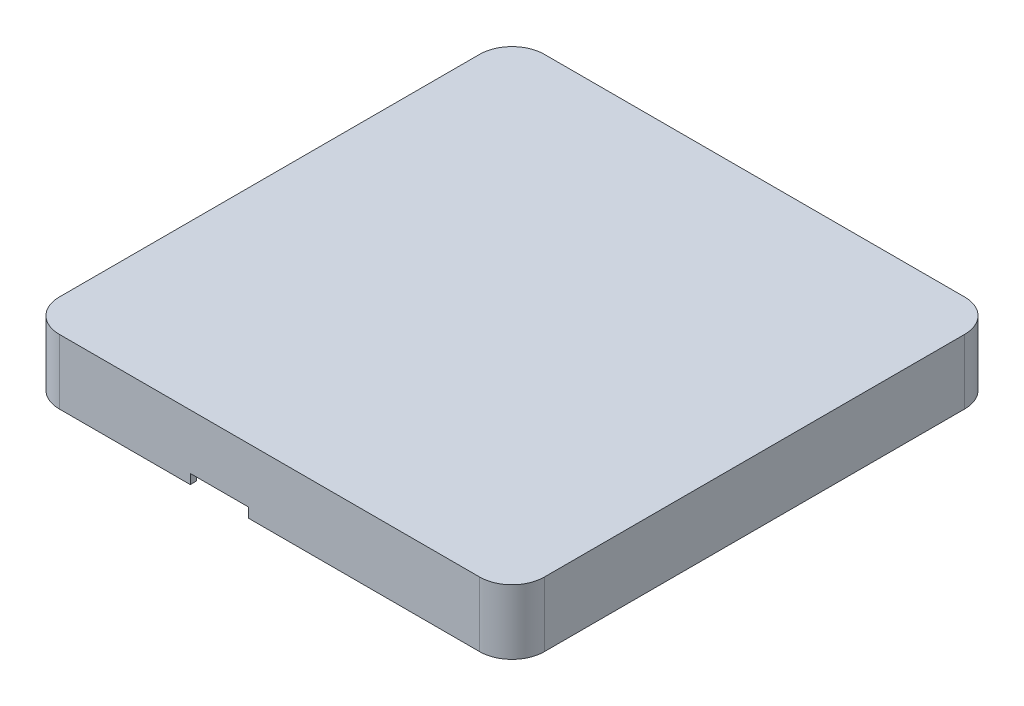
from build123d import *

# Parameters (mm, degrees)
SZKIC1_W                    = 75
SZKIC1_H                    = 75
DODANIE_WYCI_GNI_CIE1_DEPTH = 10
ZAOKR_GLENIE1_R             = 5
WYTNIJ_WYCI_GNI_CIE1_DEPTH  = 8
WYTNIJ_WYCI_GNI_CIE2_DEPTH  = 4
SZKIC7_R                    = 1.9
SZKIC7_R_2                  = 0.9
SZKIC7_R_3                  = 1.900523095
SZKIC7_R_4                  = 0.900523095
DODANIE_WYCI_GNI_CIE2_DEPTH = 8.7
SZKIC9_R                    = 0.900523095
SZKIC9_R_2                  = 0.9
DODANIE_WYCI_GNI_CIE3_DEPTH = 1
SZKIC10_R                   = 1.7
DODANIE_WYCI_GNI_CIE4_DEPTH = 1
SZKIC11_R                   = 2.45
SZKIC11_R_2                 = 1.7
DODANIE_WYCI_GNI_CIE5_DEPTH = 8.5
SZKIC19_W                   = 9
SZKIC19_H                   = 1.5
WYTNIJ_WYCI_GNI_CIE15_DEPTH = 10
SZKIC22_W                   = 4
SZKIC22_H                   = 1
DODANIE_WYCI_GNI_CIE6_DEPTH = 0.3
SZKIC24_W                   = 4
SZKIC24_H                   = 1
DODANIE_WYCI_GNI_CIE7_DEPTH = 0.3
WYTNIJ_WYCI_GNI_CIE13_DEPTH = 55
WYTNIJ_WYCI_GNI_CIE14_DEPTH = 55


with BuildPart() as part:
    # Szkic1 → Dodanie-wyciągnięcie1 (new body)
    with BuildSketch(Plane(origin=(0, 0, 0), x_dir=(1, 0, 0), z_dir=(0, 1, 0))):
        with Locations((37.5, 37.5)):
            Rectangle(SZKIC1_W, SZKIC1_H)
    extrude(amount=DODANIE_WYCI_GNI_CIE1_DEPTH)

    # Zaokrąglenie1
    zaokr_glenie1_edges = [part.edges().sort_by_distance(p)[0] for p in [
        (0, 5, 0),
        (0, 5, -75),
        (75, 5, -75),
        (75, 5, 0),
    ]]
    fillet(zaokr_glenie1_edges, radius=ZAOKR_GLENIE1_R)

    # Szkic4 → Wytnij-wyciągnięcie1 (cut)
    with BuildSketch(Plane(origin=(0, 10, 0), x_dir=(1, 0, 0), z_dir=(0, 1, 0))):
        with BuildLine():
            Line((2, 70), (2, 5))
            ThreePointArc((2, 5), (2.878679656, 2.878679656), (5, 2))
            Line((5, 2), (70, 2))
            ThreePointArc((70, 2), (72.121320344, 2.878679656), (73, 5))
            Line((73, 5), (73, 70))
            ThreePointArc((73, 70), (72.121320344, 72.121320344), (70, 73))
            Line((70, 73), (5, 73))
            ThreePointArc((5, 73), (2.878679656, 72.121320344), (2, 70))
        make_face()
    extrude(amount=-WYTNIJ_WYCI_GNI_CIE1_DEPTH, mode=Mode.SUBTRACT)

    # Szkic6 → Wytnij-wyciągnięcie2 (cut)
    with BuildSketch(Plane(origin=(0, 10, 0), x_dir=(1, 0, 0), z_dir=(0, 1, 0))):
        with BuildLine():
            Line((1, 70), (1, 5))
            ThreePointArc((1, 5), (2.171572875, 2.171572875), (5, 1))
            Line((5, 1), (70, 1))
            ThreePointArc((70, 1), (72.828427125, 2.171572875), (74, 5))
            Line((74, 5), (74, 70))
            ThreePointArc((74, 70), (72.828427125, 72.828427125), (70, 74))
            Line((70, 74), (5, 74))
            ThreePointArc((5, 74), (2.171572875, 72.828427125), (1, 70))
        make_face()
        with BuildLine():
            Line((2, 70), (2, 5))
            ThreePointArc((2, 5), (2.878679656, 2.878679656), (5, 2))
            Line((5, 2), (70, 2))
            ThreePointArc((70, 2), (72.121320344, 2.878679656), (73, 5))
            Line((73, 5), (73, 70))
            ThreePointArc((73, 70), (72.121320344, 72.121320344), (70, 73))
            Line((70, 73), (5, 73))
            ThreePointArc((5, 73), (2.878679656, 72.121320344), (2, 70))
        make_face(mode=Mode.SUBTRACT)
    extrude(amount=-WYTNIJ_WYCI_GNI_CIE2_DEPTH, mode=Mode.SUBTRACT)

    # Szkic7 → Dodanie-wyciągnięcie2 (add)
    with BuildSketch(Plane(origin=(0, 2, 0), x_dir=(1, 0, 0), z_dir=(0, 1, 0))):
        with Locations((24, 52)):
            Circle(SZKIC7_R)
        with Locations((24, 52)):
            Circle(SZKIC7_R_2, mode=Mode.SUBTRACT)
        with Locations((35.5, 52)):
            Circle(SZKIC7_R_3)
        with Locations((35.5, 52)):
            Circle(SZKIC7_R_4, mode=Mode.SUBTRACT)
        with Locations((35.5, 5)):
            Circle(SZKIC7_R)
        with Locations((35.5, 5)):
            Circle(SZKIC7_R_2, mode=Mode.SUBTRACT)
        with Locations((24, 5)):
            Circle(SZKIC7_R)
        with Locations((24, 5)):
            Circle(SZKIC7_R_2, mode=Mode.SUBTRACT)
    extrude(amount=DODANIE_WYCI_GNI_CIE2_DEPTH)

    # Szkic9 → Dodanie-wyciągnięcie3 (add)
    with BuildSketch(Plane(origin=(0, 2, 0), x_dir=(1, 0, 0), z_dir=(0, 1, 0))):
        with Locations((35.5, 52)):
            Circle(SZKIC9_R)
        with Locations((35.5, 5)):
            Circle(SZKIC9_R_2)
        with Locations((24, 5)):
            Circle(SZKIC9_R_2)
        with Locations((24, 52)):
            Circle(SZKIC9_R_2)
    extrude(amount=DODANIE_WYCI_GNI_CIE3_DEPTH)

    # Szkic10 → Dodanie-wyciągnięcie4 (add)
    with BuildSketch(Plane(origin=(0, 2, 0), x_dir=(1, 0, 0), z_dir=(0, 1, 0))):
        with Locations((67, 17)):
            Circle(SZKIC10_R)
        with Locations((67, 8)):
            Circle(SZKIC10_R)
    extrude(amount=DODANIE_WYCI_GNI_CIE4_DEPTH)

    # Szkic11 → Dodanie-wyciągnięcie5 (add)
    with BuildSketch(Plane(origin=(0, 2, 0), x_dir=(1, 0, 0), z_dir=(0, 1, 0))):
        with Locations((67, 17)):
            Circle(SZKIC11_R)
        with Locations((67, 17)):
            Circle(SZKIC11_R_2, mode=Mode.SUBTRACT)
        with Locations((67, 8)):
            Circle(SZKIC11_R)
        with Locations((67, 8)):
            Circle(SZKIC11_R_2, mode=Mode.SUBTRACT)
    extrude(amount=DODANIE_WYCI_GNI_CIE5_DEPTH)

    # Szkic19 → Wytnij-wyciągnięcie15 (cut)
    with BuildSketch(Plane(origin=(0, 0, -2), x_dir=(-1, 0, 0), z_dir=(0, 0, -1))):
        with Locations((-29.75, 9.25)):
            Rectangle(SZKIC19_W, SZKIC19_H)
    extrude(amount=-WYTNIJ_WYCI_GNI_CIE15_DEPTH, mode=Mode.SUBTRACT)

    # Szkic22 → Dodanie-wyciągnięcie6 (add)
    with BuildSketch(Plane.ZY.offset(-74)):
        with Locations((-37.5, 9.5)):
            Rectangle(SZKIC22_W, SZKIC22_H)
        with Locations((-63, 9.5)):
            Rectangle(SZKIC22_W, SZKIC22_H)
        with Locations((-12, 9.5)):
            Rectangle(SZKIC22_W, SZKIC22_H)
    extrude(amount=DODANIE_WYCI_GNI_CIE6_DEPTH)

    # Szkic24 → Dodanie-wyciągnięcie7 (add)
    with BuildSketch(Plane(origin=(1, 0, 0), x_dir=(0, 0, -1), z_dir=(1, 0, 0))):
        with Locations((12, 9.5)):
            Rectangle(SZKIC24_W, SZKIC24_H)
        with Locations((63, 9.5)):
            Rectangle(SZKIC24_W, SZKIC24_H)
        with Locations((37.5, 9.5)):
            Rectangle(SZKIC24_W, SZKIC24_H)
    extrude(amount=DODANIE_WYCI_GNI_CIE7_DEPTH)

    # Szkic25 → Wytnij-wyciągnięcie13 (cut)
    with BuildSketch(Plane.XY.offset(-10)):
        Polygon((1, 10), (1.3, 9.5), (1.3, 10), align=None)
    extrude(amount=-WYTNIJ_WYCI_GNI_CIE13_DEPTH, mode=Mode.SUBTRACT)

    # Szkic26 → Wytnij-wyciągnięcie14 (cut)
    with BuildSketch(Plane(origin=(0, 0, -65), x_dir=(-1, 0, 0), z_dir=(0, 0, -1))):
        Polygon((-74, 10), (-73.7, 10), (-73.7, 9.5), align=None)
    extrude(amount=-WYTNIJ_WYCI_GNI_CIE14_DEPTH, mode=Mode.SUBTRACT)


with BuildPart() as body_2:
    # Lustro5: mirrored copy
    add(part.part.mirror(Plane.ZX.offset(-10)))


solid = body_2.part
